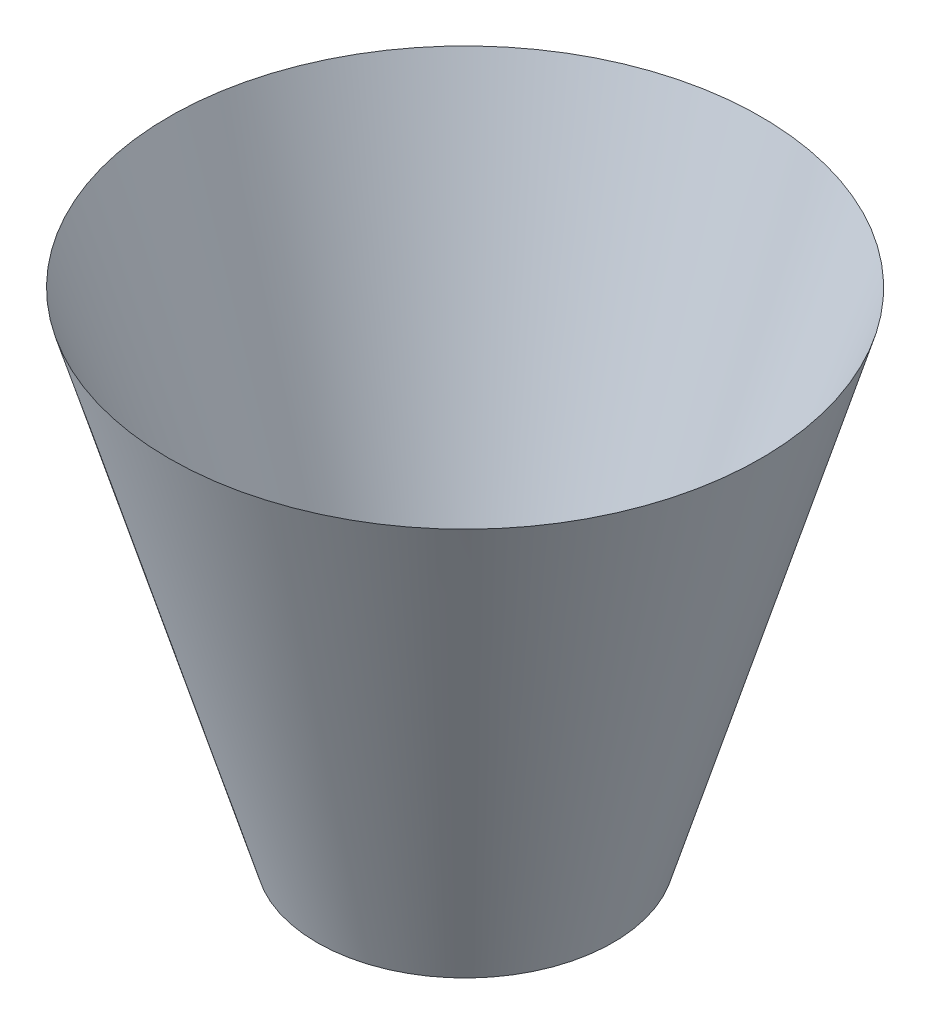
from build123d import *

# Parameters (mm, degrees)
SKETCH_1_R = 300
SKETCH_2_R = 600
SKETCH_3_R = 250


with BuildPart() as part:
    # 草图1 → Loft 1 section 0
    with BuildSketch(Plane(origin=(0, 0, 0), x_dir=(1, 0, 0), z_dir=(0, 1, 0))):
        Circle(SKETCH_1_R)
    # 草图2 → Loft 1 section 1
    with BuildSketch(Plane(origin=(0, 1000, 0), x_dir=(1, 0, 0), z_dir=(0, 1, 0))):
        Circle(SKETCH_2_R)
    loft()

    # 草图3 → section 0 of loft_1_2
    with BuildSketch(Plane(origin=(0, 0, 0), x_dir=(1, 0, 0), z_dir=(0, 1, 0)), mode=Mode.PRIVATE) as loft_1_2_s0:
        Circle(SKETCH_3_R)
    # loft up to a face of the part (loft_1_2)
    loft([loft_1_2_s0.sketch, Face(Wire([part.edges().sort_by_distance((-410.728263557, 1000, -437.381176453))[0]]))], mode=Mode.SUBTRACT)


solid = part.part
